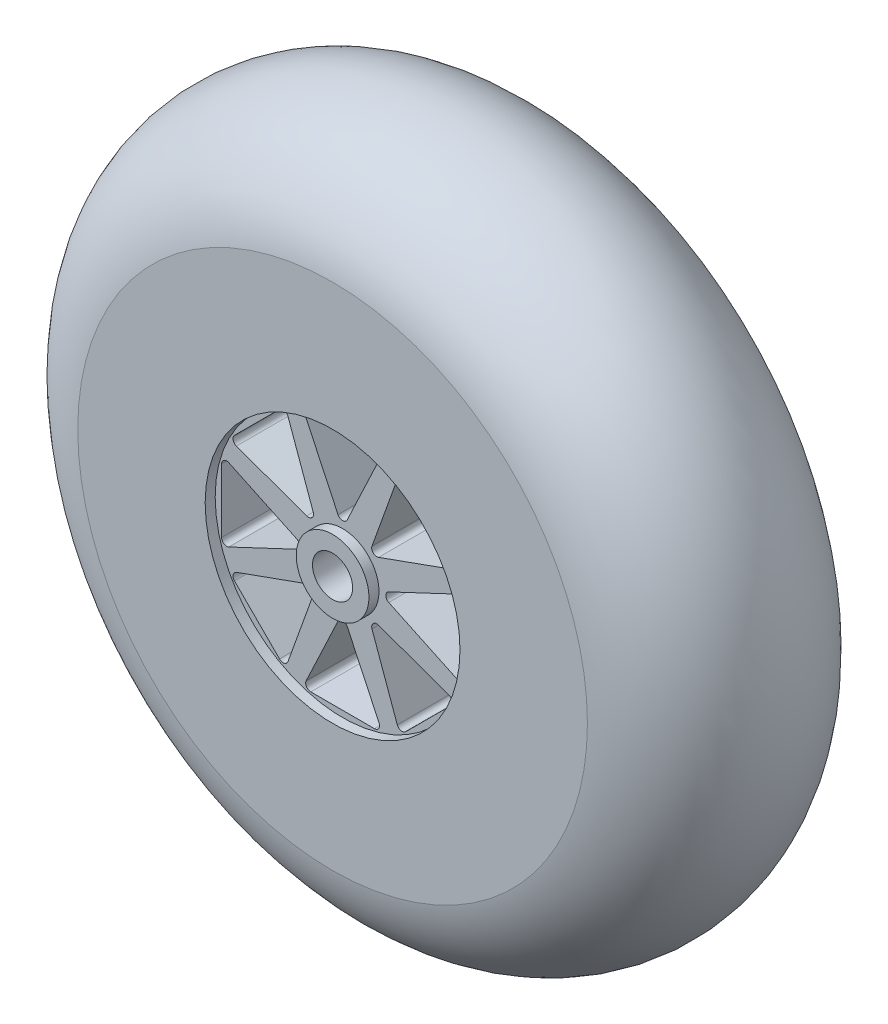
from build123d import *

# Parameters (mm, degrees)
SKETCH2_R          = 12.7
SKETCH2_R_2        = 3.625
CUT_EXTRUDE1_DEPTH = 1
CUT_EXTRUDE2_DEPTH = 9.525


with BuildPart() as part:
    # Sketch1 → Revolve1 (revolve)
    with BuildSketch(Plane(origin=(0, 0, 0), x_dir=(0, 0, -1), z_dir=(1, 0, 0))):
        with BuildLine():
            Line((0, 25.4), (0, 2))
            Line((0, 2), (22.225, 2))
            Line((22.225, 2), (22.225, 25.4))
            ThreePointArc((22.225, 25.4), (11.1125, 34.925), (0, 25.4))
        make_face()
    revolve(axis=Axis((0, 0, -22.225), (0, 0, 1)))

    # Sketch2 → Cut-Extrude1 (cut)
    with BuildSketch(Plane.XY):
        Circle(SKETCH2_R)
        Circle(SKETCH2_R_2, mode=Mode.SUBTRACT)
    extrude(amount=-CUT_EXTRUDE1_DEPTH, mode=Mode.SUBTRACT)

    # Sketch3 → Cut-Extrude2 (cut)
    with BuildSketch(Plane.XY.offset(-1)):
        with BuildLine():
            Line((-0.459525068, 4.600054071), (-3.634525068, 11.337002474))
            ThreePointArc((-3.634525068, 11.337002474), (-3.603998477, 11.825642279), (-3.175, 12.061568196))
            Line((-3.175, 12.061568196), (3.175, 12.061568196))
            ThreePointArc((3.175, 12.061568196), (3.603998477, 11.825642279), (3.634525068, 11.337002474))
            Line((3.634525068, 11.337002474), (0.459525068, 4.600054071))
            ThreePointArc((0.459525068, 4.600054071), (0, 4.308619792), (-0.459525068, 4.600054071))
        make_face()
        with BuildLine():
            Line((3.577662719, 2.927796135), (10.58646865, 5.446474006))
            ThreePointArc((10.58646865, 5.446474006), (10.91040361, 5.813580085), (10.773880693, 6.283752633))
            Line((10.773880693, 6.283752633), (6.283752633, 10.773880693))
            ThreePointArc((6.283752633, 10.773880693), (5.813580085, 10.91040361), (5.446474006, 10.58646865))
            Line((5.446474006, 10.58646865), (2.927796135, 3.577662719))
            ThreePointArc((2.927796135, 3.577662719), (3.046654273, 3.046654273), (3.577662719, 2.927796135))
        make_face()
        with BuildLine():
            Line((4.600054071, -0.459525068), (11.337002474, -3.634525068))
            ThreePointArc((11.337002474, -3.634525068), (11.825642279, -3.603998477), (12.061568196, -3.175))
            Line((12.061568196, -3.175), (12.061568196, 3.175))
            ThreePointArc((12.061568196, 3.175), (11.825642279, 3.603998477), (11.337002474, 3.634525068))
            Line((11.337002474, 3.634525068), (4.600054071, 0.459525068))
            ThreePointArc((4.600054071, 0.459525068), (4.308619792, 0), (4.600054071, -0.459525068))
        make_face()
        with BuildLine():
            Line((2.927796135, -3.577662719), (5.446474006, -10.58646865))
            ThreePointArc((5.446474006, -10.58646865), (5.813580085, -10.91040361), (6.283752633, -10.773880693))
            Line((6.283752633, -10.773880693), (10.773880693, -6.283752633))
            ThreePointArc((10.773880693, -6.283752633), (10.91040361, -5.813580085), (10.58646865, -5.446474006))
            Line((10.58646865, -5.446474006), (3.577662719, -2.927796135))
            ThreePointArc((3.577662719, -2.927796135), (3.046654273, -3.046654273), (2.927796135, -3.577662719))
        make_face()
        with BuildLine():
            Line((-0.459525068, -4.600054071), (-3.634525068, -11.337002474))
            ThreePointArc((-3.634525068, -11.337002474), (-3.603998477, -11.825642279), (-3.175, -12.061568196))
            Line((-3.175, -12.061568196), (3.175, -12.061568196))
            ThreePointArc((3.175, -12.061568196), (3.603998477, -11.825642279), (3.634525068, -11.337002474))
            Line((3.634525068, -11.337002474), (0.459525068, -4.600054071))
            ThreePointArc((0.459525068, -4.600054071), (0, -4.308619792), (-0.459525068, -4.600054071))
        make_face()
        with BuildLine():
            Line((-3.577662719, -2.927796135), (-10.58646865, -5.446474006))
            ThreePointArc((-10.58646865, -5.446474006), (-10.91040361, -5.813580085), (-10.773880693, -6.283752633))
            Line((-10.773880693, -6.283752633), (-6.283752633, -10.773880693))
            ThreePointArc((-6.283752633, -10.773880693), (-5.813580085, -10.91040361), (-5.446474006, -10.58646865))
            Line((-5.446474006, -10.58646865), (-2.927796135, -3.577662719))
            ThreePointArc((-2.927796135, -3.577662719), (-3.046654273, -3.046654273), (-3.577662719, -2.927796135))
        make_face()
        with BuildLine():
            Line((-4.600054071, 0.459525068), (-11.337002474, 3.634525068))
            ThreePointArc((-11.337002474, 3.634525068), (-11.825642279, 3.603998477), (-12.061568196, 3.175))
            Line((-12.061568196, 3.175), (-12.061568196, -3.175))
            ThreePointArc((-12.061568196, -3.175), (-11.825642279, -3.603998477), (-11.337002474, -3.634525068))
            Line((-11.337002474, -3.634525068), (-4.600054071, -0.459525068))
            ThreePointArc((-4.600054071, -0.459525068), (-4.308619792, 0), (-4.600054071, 0.459525068))
        make_face()
        with BuildLine():
            Line((-2.927796135, 3.577662719), (-5.446474006, 10.58646865))
            ThreePointArc((-5.446474006, 10.58646865), (-5.813580085, 10.91040361), (-6.283752633, 10.773880693))
            Line((-6.283752633, 10.773880693), (-10.773880693, 6.283752633))
            ThreePointArc((-10.773880693, 6.283752633), (-10.91040361, 5.813580085), (-10.58646865, 5.446474006))
            Line((-10.58646865, 5.446474006), (-3.577662719, 2.927796135))
            ThreePointArc((-3.577662719, 2.927796135), (-3.046654273, 3.046654273), (-2.927796135, 3.577662719))
        make_face()
    extrude(amount=-CUT_EXTRUDE2_DEPTH, mode=Mode.SUBTRACT)


solid = part.part
